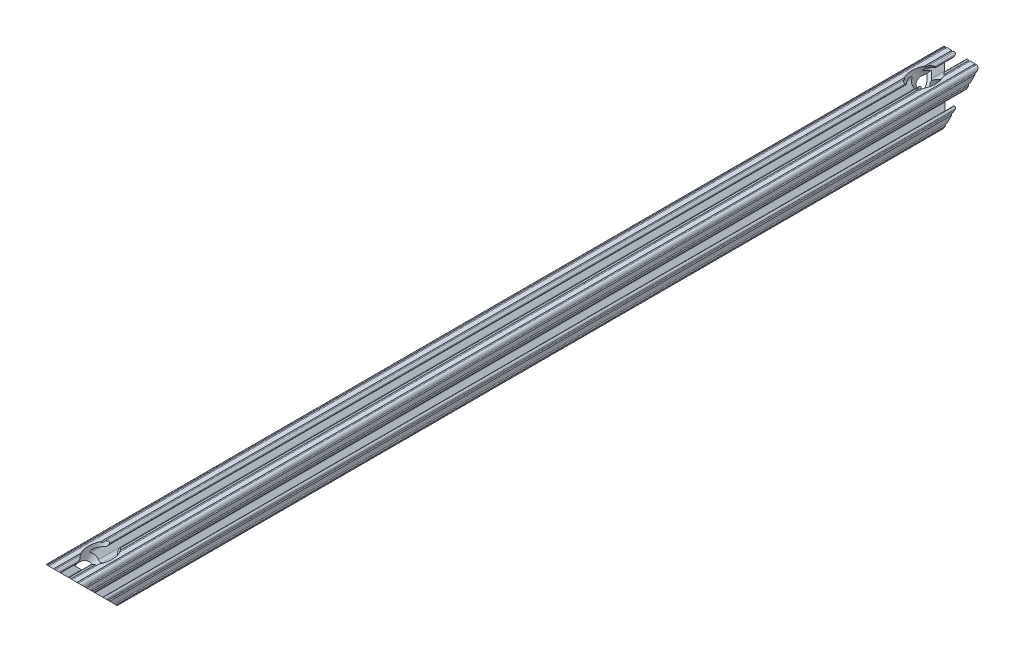
from build123d import *

# Parameters (mm, degrees)
SKETCH1_R               = 2.6035
BOSS_EXTRUDE1_DEPTH     = 304.8
CUT_EXTRUDE1_DEPTH      = 306.328708116
CUT_EXTRUDE1_DEPTH_BACK = 306.328708116
CUT_REVOLVE1_ANGLE      = 360


with BuildPart() as part:
    # Sketch1 → Boss-Extrude1 (new, symmetric)
    with BuildSketch(Plane.XY):
        with BuildLine():
            Line((-7.179650497, -8.645192506), (-3.952270251, -5.423690499))
            ThreePointArc((-3.952270251, -5.423690499), (-2.922936451, -4.736929036), (-1.709253557, -4.4958))
            Line((-1.709253557, -4.4958), (1.709253557, -4.4958))
            ThreePointArc((1.709253557, -4.4958), (2.922936451, -4.736929036), (3.952270251, -5.423690499))
            Line((3.952270251, -5.423690499), (7.179650497, -8.645192506))
            ThreePointArc((7.179650497, -8.645192506), (7.41473083, -9.822813117), (6.416408329, -10.4902))
            Line((6.416408329, -10.4902), (4.287512407, -10.4902))
            ThreePointArc((4.287512407, -10.4902), (3.54574862, -10.79744862), (3.2385, -11.539212407))
            Line((3.2385, -11.539212407), (3.2385, -11.650987593))
            ThreePointArc((3.2385, -11.650987593), (3.54574862, -12.39275138), (4.287512407, -12.7))
            Line((4.287512407, -12.7), (5.317126718, -12.7))
            ThreePointArc((5.317126718, -12.7), (5.825126718, -12.192), (6.333126718, -12.7))
            Line((6.333126718, -12.7), (9.550443118, -12.7))
            ThreePointArc((9.550443118, -12.7), (10.058366869, -12.192000006), (10.566443095, -12.699847501))
            ThreePointArc((10.566443095, -12.699847501), (12.082537762, -12.08250727), (12.699846982, -10.566399977))
            ThreePointArc((12.699846982, -10.566399977), (12.192000006, -10.058323491), (12.7, -9.5504))
            Line((12.7, -9.5504), (12.7, -6.3330836))
            ThreePointArc((12.7, -6.3330836), (12.192, -5.8250836), (12.7, -5.3170836))
            Line((12.7, -5.3170836), (12.7, -4.287469289))
            ThreePointArc((12.7, -4.287469289), (12.39275138, -3.545705502), (11.650987593, -3.238456882))
            Line((11.650987593, -3.238456882), (11.539212407, -3.238456882))
            ThreePointArc((11.539212407, -3.238456882), (10.79744862, -3.545705502), (10.4902, -4.287469289))
            Line((10.4902, -4.287469289), (10.4902, -6.402089023))
            ThreePointArc((10.4902, -6.402089023), (9.856505071, -7.351067942), (8.737131347, -7.129408934))
            Line((8.737131347, -7.129408934), (5.441005833, -3.840816462))
            ThreePointArc((5.441005833, -3.840816462), (4.750877967, -2.809883091), (4.5085, -1.593185507))
            Line((4.5085, -1.593185507), (4.5085, 1.593185507))
            ThreePointArc((4.5085, 1.593185507), (4.750877967, 2.809883091), (5.441005833, 3.840816462))
            Line((5.441005833, 3.840816462), (8.737131347, 7.129408934))
            ThreePointArc((8.737131347, 7.129408934), (9.856505071, 7.351067942), (10.4902, 6.402089023))
            Line((10.4902, 6.402089023), (10.4902, 4.287469289))
            ThreePointArc((10.4902, 4.287469289), (10.79744862, 3.545705502), (11.539212407, 3.238456882))
            Line((11.539212407, 3.238456882), (11.650987593, 3.238456882))
            ThreePointArc((11.650987593, 3.238456882), (12.39275138, 3.545705502), (12.7, 4.287469289))
            Line((12.7, 4.287469289), (12.7, 5.3170836))
            ThreePointArc((12.7, 5.3170836), (12.192, 5.8250836), (12.7, 6.3330836))
            Line((12.7, 6.3330836), (12.7, 9.5504))
            ThreePointArc((12.7, 9.5504), (12.192000006, 10.058323491), (12.699846982, 10.566399977))
            ThreePointArc((12.699846982, 10.566399977), (12.082537762, 12.08250727), (10.566443095, 12.699847501))
            ThreePointArc((10.566443095, 12.699847501), (10.058366869, 12.192000006), (9.550443118, 12.7))
            Line((9.550443118, 12.7), (6.333126718, 12.7))
            ThreePointArc((6.333126718, 12.7), (5.825126718, 12.192), (5.317126718, 12.7))
            Line((5.317126718, 12.7), (4.287512407, 12.7))
            ThreePointArc((4.287512407, 12.7), (3.54574862, 12.39275138), (3.2385, 11.650987593))
            Line((3.2385, 11.650987593), (3.2385, 11.539212407))
            ThreePointArc((3.2385, 11.539212407), (3.54574862, 10.79744862), (4.287512407, 10.4902))
            Line((4.287512407, 10.4902), (6.476788598, 10.4902))
            ThreePointArc((6.476788598, 10.4902), (7.432222385, 9.85140422), (7.207036008, 8.724370562))
            Line((7.207036008, 8.724370562), (3.898272566, 5.423169045))
            ThreePointArc((3.898272566, 5.423169045), (2.869120213, 4.736787962), (1.655778399, 4.4958))
            Line((1.655778399, 4.4958), (-1.655778399, 4.4958))
            ThreePointArc((-1.655778399, 4.4958), (-2.869120213, 4.736787962), (-3.898272566, 5.423169045))
            Line((-3.898272566, 5.423169045), (-7.207036008, 8.724370562))
            ThreePointArc((-7.207036008, 8.724370562), (-7.432222385, 9.85140422), (-6.476788598, 10.4902))
            Line((-6.476788598, 10.4902), (-4.287512407, 10.4902))
            ThreePointArc((-4.287512407, 10.4902), (-3.54574862, 10.79744862), (-3.2385, 11.539212407))
            Line((-3.2385, 11.539212407), (-3.2385, 11.650987593))
            ThreePointArc((-3.2385, 11.650987593), (-3.54574862, 12.39275138), (-4.287512407, 12.7))
            Line((-4.287512407, 12.7), (-5.317126718, 12.7))
            ThreePointArc((-5.317126718, 12.7), (-5.825126718, 12.192), (-6.333126718, 12.7))
            Line((-6.333126718, 12.7), (-9.550443118, 12.7))
            ThreePointArc((-9.550443118, 12.7), (-10.058366869, 12.192000006), (-10.566443095, 12.699847501))
            ThreePointArc((-10.566443095, 12.699847501), (-12.082537762, 12.08250727), (-12.699846982, 10.566399977))
            ThreePointArc((-12.699846982, 10.566399977), (-12.192000006, 10.058323491), (-12.7, 9.5504))
            Line((-12.7, 9.5504), (-12.7, 6.3330836))
            ThreePointArc((-12.7, 6.3330836), (-12.192, 5.8250836), (-12.7, 5.3170836))
            Line((-12.7, 5.3170836), (-12.7, 4.287469289))
            ThreePointArc((-12.7, 4.287469289), (-12.39275138, 3.545705502), (-11.650987593, 3.238456882))
            Line((-11.650987593, 3.238456882), (-11.539212407, 3.238456882))
            ThreePointArc((-11.539212407, 3.238456882), (-10.79744862, 3.545705502), (-10.4902, 4.287469289))
            Line((-10.4902, 4.287469289), (-10.4902, 6.402089023))
            ThreePointArc((-10.4902, 6.402089023), (-9.856505071, 7.351067942), (-8.737131347, 7.129408934))
            Line((-8.737131347, 7.129408934), (-5.441005833, 3.840816462))
            ThreePointArc((-5.441005833, 3.840816462), (-4.750877967, 2.809883091), (-4.5085, 1.593185507))
            Line((-4.5085, 1.593185507), (-4.5085, -1.593185507))
            ThreePointArc((-4.5085, -1.593185507), (-4.750877967, -2.809883091), (-5.441005833, -3.840816462))
            Line((-5.441005833, -3.840816462), (-8.737131347, -7.129408934))
            ThreePointArc((-8.737131347, -7.129408934), (-9.856505071, -7.351067942), (-10.4902, -6.402089023))
            Line((-10.4902, -6.402089023), (-10.4902, -4.287469289))
            ThreePointArc((-10.4902, -4.287469289), (-10.79744862, -3.545705502), (-11.539212407, -3.238456882))
            Line((-11.539212407, -3.238456882), (-11.650987593, -3.238456882))
            ThreePointArc((-11.650987593, -3.238456882), (-12.39275138, -3.545705502), (-12.7, -4.287469289))
            Line((-12.7, -4.287469289), (-12.7, -5.3170836))
            ThreePointArc((-12.7, -5.3170836), (-12.192, -5.8250836), (-12.7, -6.3330836))
            Line((-12.7, -6.3330836), (-12.7, -9.5504))
            ThreePointArc((-12.7, -9.5504), (-12.192000006, -10.058323491), (-12.699846982, -10.566399977))
            ThreePointArc((-12.699846982, -10.566399977), (-12.082537762, -12.08250727), (-10.566443095, -12.699847501))
            ThreePointArc((-10.566443095, -12.699847501), (-10.058366869, -12.192000006), (-9.550443118, -12.7))
            Line((-9.550443118, -12.7), (-6.333126718, -12.7))
            ThreePointArc((-6.333126718, -12.7), (-5.825126718, -12.192), (-5.317126718, -12.7))
            Line((-5.317126718, -12.7), (-4.287512407, -12.7))
            ThreePointArc((-4.287512407, -12.7), (-3.54574862, -12.39275138), (-3.2385, -11.650987593))
            Line((-3.2385, -11.650987593), (-3.2385, -11.539212407))
            ThreePointArc((-3.2385, -11.539212407), (-3.54574862, -10.79744862), (-4.287512407, -10.4902))
            Line((-4.287512407, -10.4902), (-6.416408329, -10.4902))
            ThreePointArc((-6.416408329, -10.4902), (-7.41473083, -9.822813117), (-7.179650497, -8.645192506))
        make_face()
        with Locations(Location((0, 0, 0), (0, 0, 180))):
            Circle(SKETCH1_R, mode=Mode.SUBTRACT)
    extrude(amount=BOSS_EXTRUDE1_DEPTH, both=True)

    # Sketch2 → Cut-Extrude1 (cut, two sides)
    with BuildSketch(Plane(origin=(0, 0, 0), x_dir=(0, 0, -1), z_dir=(1, 0, 0))) as cut_extrude1_sk:
        Polygon((-304.8, 12.699847501), (-304.8, -12.7), (-279.400152499, -12.7), align=None)
        Polygon((279.400152499, -12.7), (304.8, 12.699847501), (304.8, -12.7), align=None)
    extrude(amount=CUT_EXTRUDE1_DEPTH, mode=Mode.SUBTRACT)
    extrude(cut_extrude1_sk.sketch, amount=-CUT_EXTRUDE1_DEPTH_BACK, mode=Mode.SUBTRACT)

    # Sketch3 → Cut-Revolve1 (revolve, symmetric, cut)
    with BuildSketch(Plane(origin=(0, 0, 0), x_dir=(0, 0, -1), z_dir=(1, 0, 0))) as cut_revolve1_sk:
        Polygon((-273.787644922, 18.312507577), (-292.100152499, 0), (-294.408078322, 2.307925823), (-289.917950261, 6.798053884), (-293.222684514, 10.102788136), (-279.400304998, 23.925167653), align=None)
    cut_revolve1 = revolve(axis=Axis((0, 0, 292.100152499), (0, -0.7071067811865456, 0.7071067811865495)), revolution_arc=CUT_REVOLVE1_ANGLE / 2, mode=Mode.SUBTRACT)
    cut_revolve1 = cut_revolve1 + revolve(cut_revolve1_sk.sketch, axis=Axis((0, 0, 292.100152499), (0, 0.7071067811865456, -0.7071067811865495)), revolution_arc=CUT_REVOLVE1_ANGLE / 2, mode=Mode.SUBTRACT)

    # Mirror1: Cut-Revolve1 across plane
    add(cut_revolve1.mirror(Plane.XY), mode=Mode.SUBTRACT)


solid = part.part
